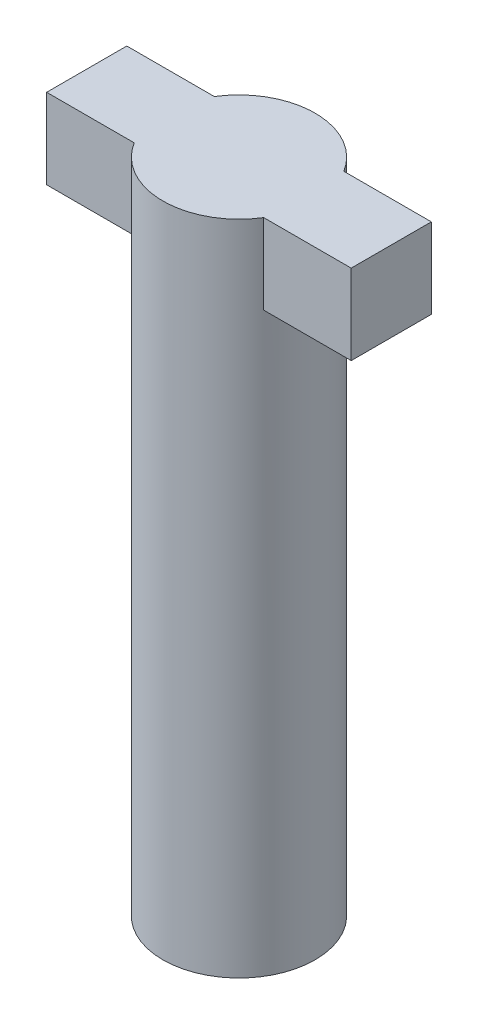
from build123d import *

# Parameters (mm, degrees)
SKETCH1_R  = 0.95
BODY_DEPTH = 8.2
LOCK_DEPTH = 1


with BuildPart() as part:
    # Sketch1 → Body (new body)
    with BuildSketch(Plane(origin=(0, 0, 0), x_dir=(1, 0, 0), z_dir=(0, 1, 0))):
        Circle(SKETCH1_R)
    extrude(amount=BODY_DEPTH)

    # Sketch2 → Lock (add)
    with BuildSketch(Plane(origin=(0, 8.2, 0), x_dir=(1, 0, 0), z_dir=(0, 1, 0))):
        with BuildLine():
            ThreePointArc((-0.807774721, -0.5), (-0.95, 0), (-0.807774721, 0.5))
            Line((-0.807774721, 0.5), (-1.9, 0.5))
            Line((-1.9, 0.5), (-1.9, -0.5))
            Line((-1.9, -0.5), (-0.807774721, -0.5))
        make_face()
        with BuildLine():
            Line((1.9, 0.5), (0.807774721, 0.5))
            ThreePointArc((0.807774721, 0.5), (0.91375215, 0.259917309), (0.95, 0))
            ThreePointArc((0.95, 0), (0.91375215, -0.259917309), (0.807774721, -0.5))
            Line((0.807774721, -0.5), (1.9, -0.5))
            Line((1.9, -0.5), (1.9, 0.5))
        make_face()
    extrude(amount=-LOCK_DEPTH)


solid = part.part
